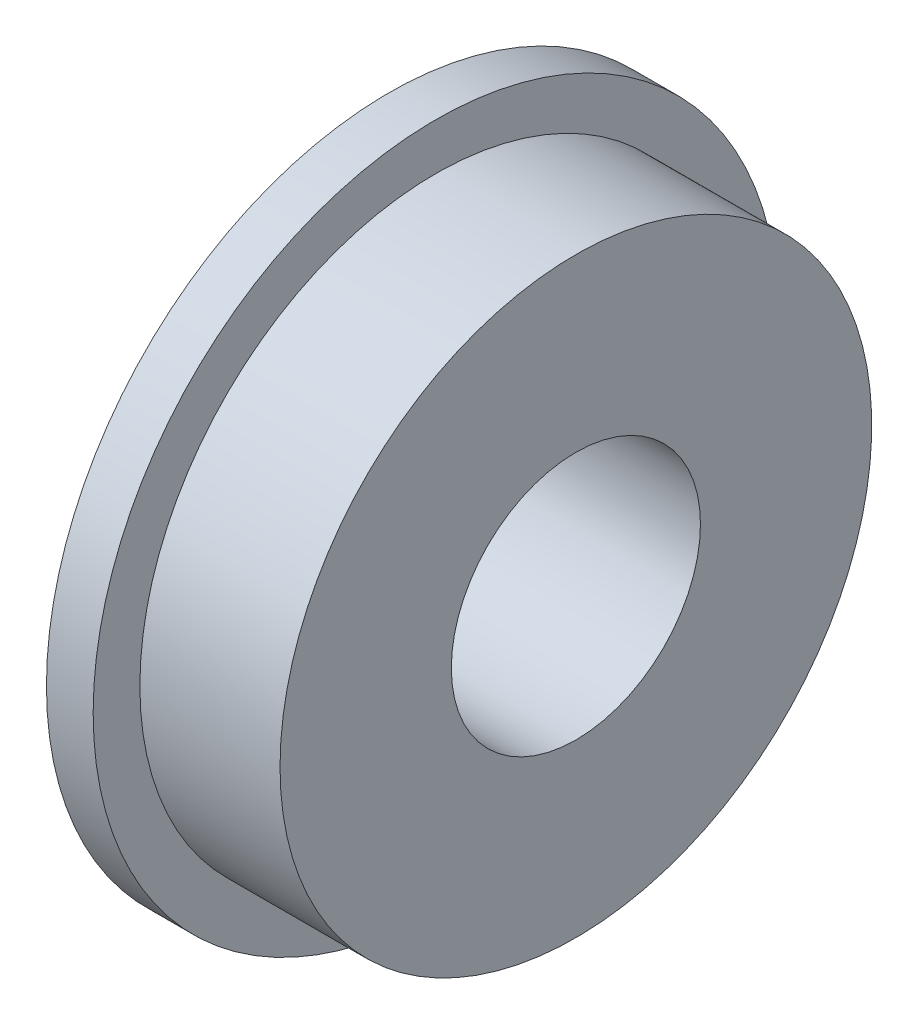
from build123d import *


with BuildPart() as part:
    # Sketch1 → Revolve1 (revolve)
    with BuildSketch(Plane(origin=(0, 0, 0), x_dir=(-1, 0, 0), z_dir=(0, 0, -1))):
        Polygon((-1.5, 9.5), (-6, 9.5), (-6, 4), (0, 4), (0, 11), (-1.5, 11), align=None)
    revolve(axis=Axis((6, 0, 0), (-1, 0, 0)))


solid = part.part
